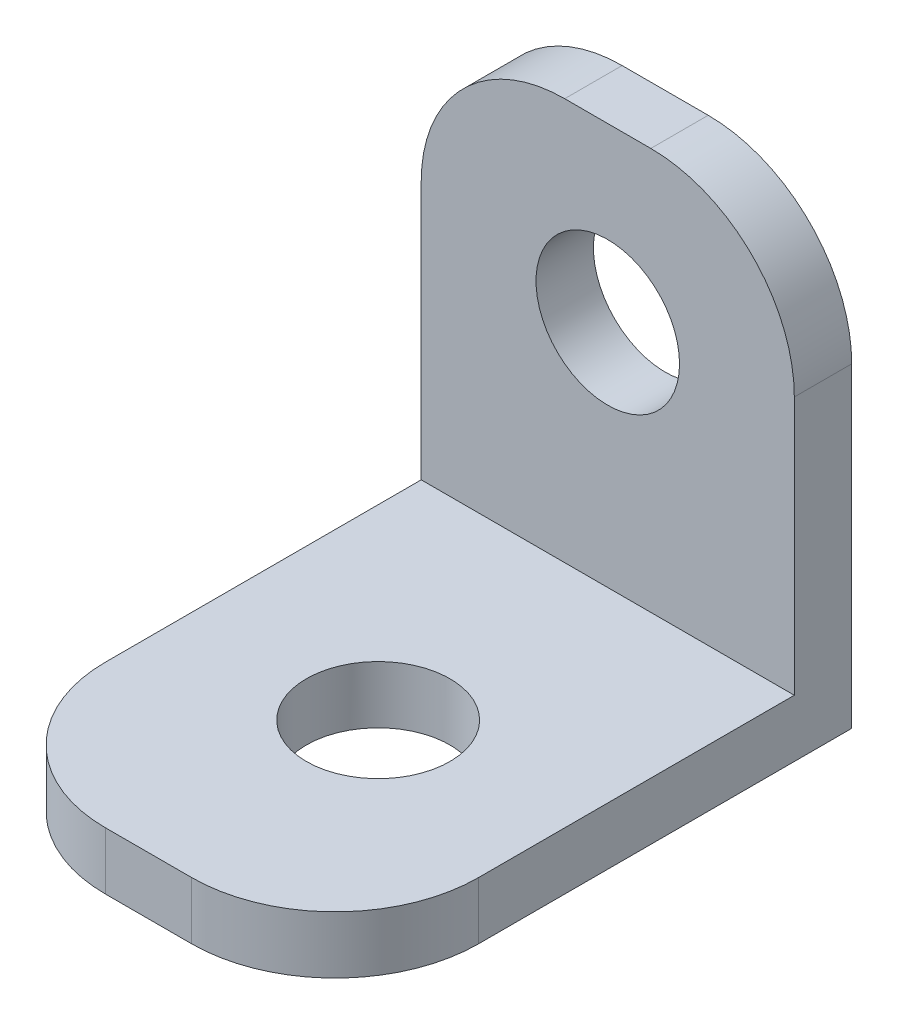
from build123d import *

# Parameters (mm, degrees)
SKETCH1_W           = 13
SKETCH1_H           = 16
SKETCH1_R           = 2.5
BOSS_EXTRUDE1_DEPTH = 2
FILLET1_R           = 5
SKETCH2_W           = 13
SKETCH2_H           = 2
BOSS_EXTRUDE2_DEPTH = 16
FILLET2_R           = 5
SKETCH3_R           = 2.5
CUT_EXTRUDE1_DEPTH  = 16


with BuildPart() as part:
    # Sketch1 → Boss-Extrude1 (new body)
    with BuildSketch(Plane.XY):
        Rectangle(SKETCH1_W, SKETCH1_H)
        with Locations((0, 2)):
            Circle(SKETCH1_R, mode=Mode.SUBTRACT)
    extrude(amount=BOSS_EXTRUDE1_DEPTH)

    # Fillet1
    fillet1_edges = [part.edges().sort_by_distance(p)[0] for p in [
        (-6.5, 8, 1),
        (6.5, 8, 1),
    ]]
    fillet(fillet1_edges, radius=FILLET1_R)

    # Sketch2 → Boss-Extrude2 (add)
    with BuildSketch(Plane.XY.offset(2)):
        with Locations((0, -7)):
            Rectangle(SKETCH2_W, SKETCH2_H)
    extrude(amount=BOSS_EXTRUDE2_DEPTH)

    # Fillet2
    fillet2_edges = [part.edges().sort_by_distance(p)[0] for p in [
        (-6.5, -7, 18),
        (6.5, -7, 18),
    ]]
    fillet(fillet2_edges, radius=FILLET2_R)

    # Sketch3 → Cut-Extrude1 (cut)
    with BuildSketch(Plane(origin=(0, -6, 0), x_dir=(1, 0, 0), z_dir=(0, 1, 0))):
        with Locations((0, -10)):
            Circle(SKETCH3_R)
    extrude(amount=-CUT_EXTRUDE1_DEPTH, mode=Mode.SUBTRACT)


solid = part.part
